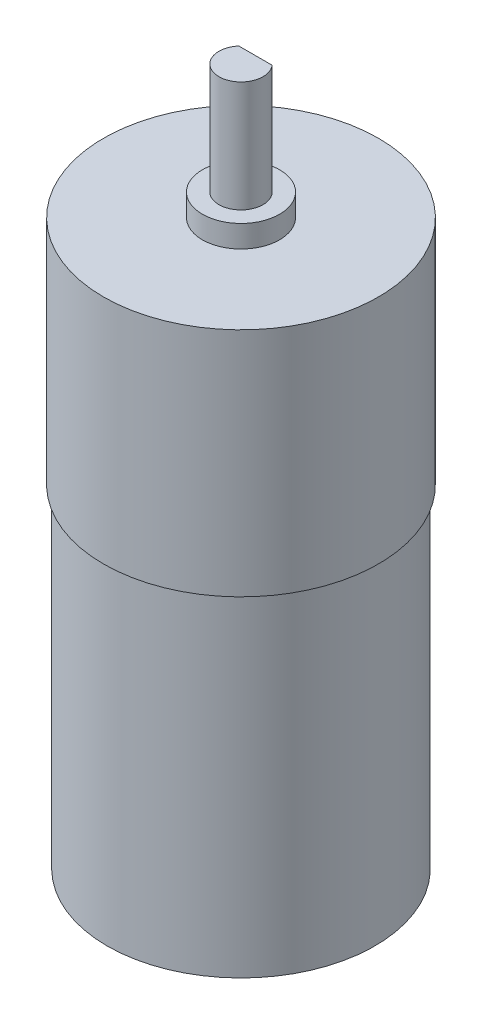
from build123d import *

# Parameters (mm, degrees)
SKETCH1_W           = 12.075
SKETCH1_H           = 30
SKETCH2_W           = 12.4
SKETCH2_H           = 20.86
SKETCH3_R           = 3.48
BOSS_EXTRUDE1_DEPTH = 2
BOSS_EXTRUDE2_DEPTH = 10


with BuildPart() as part:
    # Sketch1 → Revolve1 (revolve)
    with BuildSketch(Plane(origin=(0, 0, 0), x_dir=(0, 0, -1), z_dir=(1, 0, 0))):
        with Locations((6.0375, -16.859504132)):
            Rectangle(SKETCH1_W, SKETCH1_H)
    revolve(axis=Axis((0, 44.256198347, 0), (0, -1, 0)))

    # Sketch2 → Revolve2 (revolve)
    with BuildSketch(Plane(origin=(0, 0, 0), x_dir=(0, 0, -1), z_dir=(1, 0, 0))):
        with Locations((6.2, 8.570495868)):
            Rectangle(SKETCH2_W, SKETCH2_H)
    revolve(axis=Axis((0, -1.859504132, 0), (0, 1, 0)))

    # Sketch3 → Boss-Extrude1 (add)
    with BuildSketch(Plane(origin=(0, 19.000495868, 0), x_dir=(1, 0, 0), z_dir=(0, 1, 0))):
        Circle(SKETCH3_R)
    extrude(amount=BOSS_EXTRUDE1_DEPTH)

    # Sketch4 → Boss-Extrude2 (add)
    with BuildSketch(Plane(origin=(0, 21.000495868, 0), x_dir=(1, 0, 0), z_dir=(0, 1, 0))):
        with BuildLine():
            Line((-1.5, 1.305560373), (1.5, 1.305560373))
            ThreePointArc((1.5, 1.305560373), (0, -1.988589421), (-1.5, 1.305560373))
        make_face()
    extrude(amount=BOSS_EXTRUDE2_DEPTH)


solid = part.part
